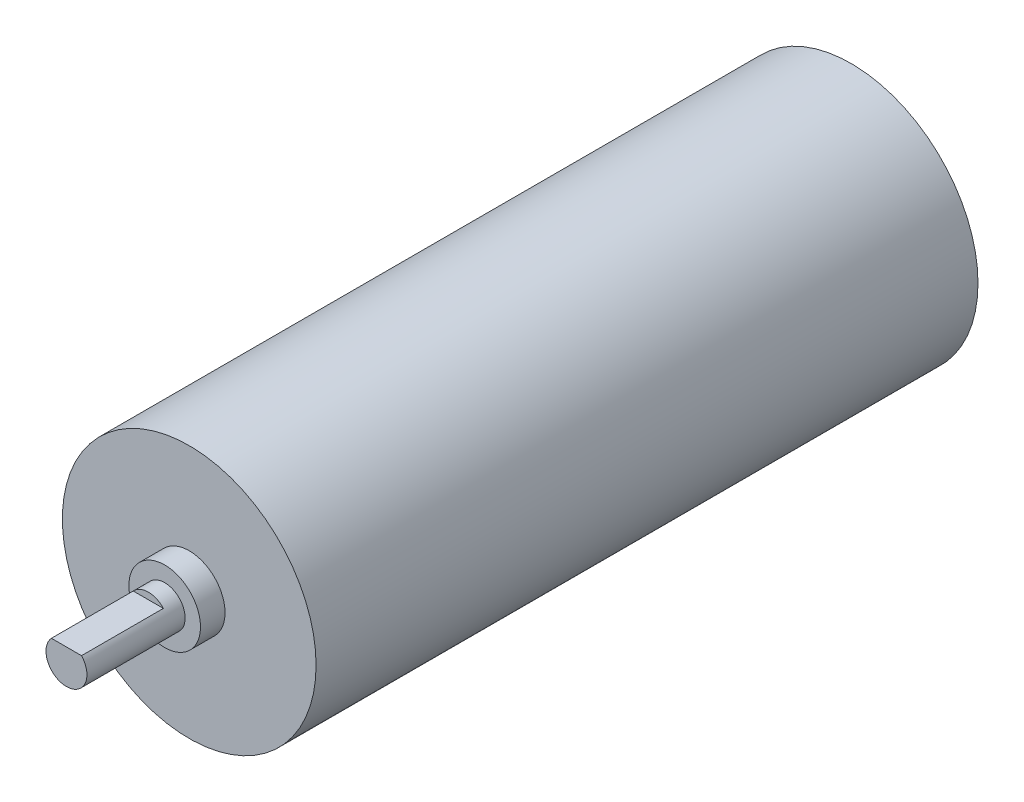
from build123d import *

# Parameters (mm, degrees)
SKETCH1_R           = 12.4
MAIN_EXTRUDE_DEPTH  = 64.7
SKETCH2_R           = 3.5
BOSS_EXTRUDE2_DEPTH = 2.4
SKETCH3_R           = 2
BOSS_EXTRUDE3_DEPTH = 9.6
KEY_CUT_DEPTH       = 8


with BuildPart() as part:
    # Sketch1 → Main Extrude (new body)
    with BuildSketch(Plane.XY):
        Circle(SKETCH1_R)
    extrude(amount=MAIN_EXTRUDE_DEPTH)

    # Sketch2 → Boss-Extrude2 (add)
    with BuildSketch(Plane.XY.offset(64.7)):
        Circle(SKETCH2_R)
    extrude(amount=BOSS_EXTRUDE2_DEPTH)

    # Sketch3 → Boss-Extrude3 (add)
    with BuildSketch(Plane.XY.offset(67.1)):
        Circle(SKETCH3_R)
    extrude(amount=BOSS_EXTRUDE3_DEPTH)

    # Sketch5 → Key Cut (cut)
    with BuildSketch(Plane.XY.offset(76.7)):
        with BuildLine():
            Line((-1.472086844, 1.353868651), (1.472086844, 1.353868651))
            ThreePointArc((1.472086844, 1.353868651), (0, 2), (-1.472086844, 1.353868651))
        make_face()
    extrude(amount=-KEY_CUT_DEPTH, mode=Mode.SUBTRACT)


solid = part.part
